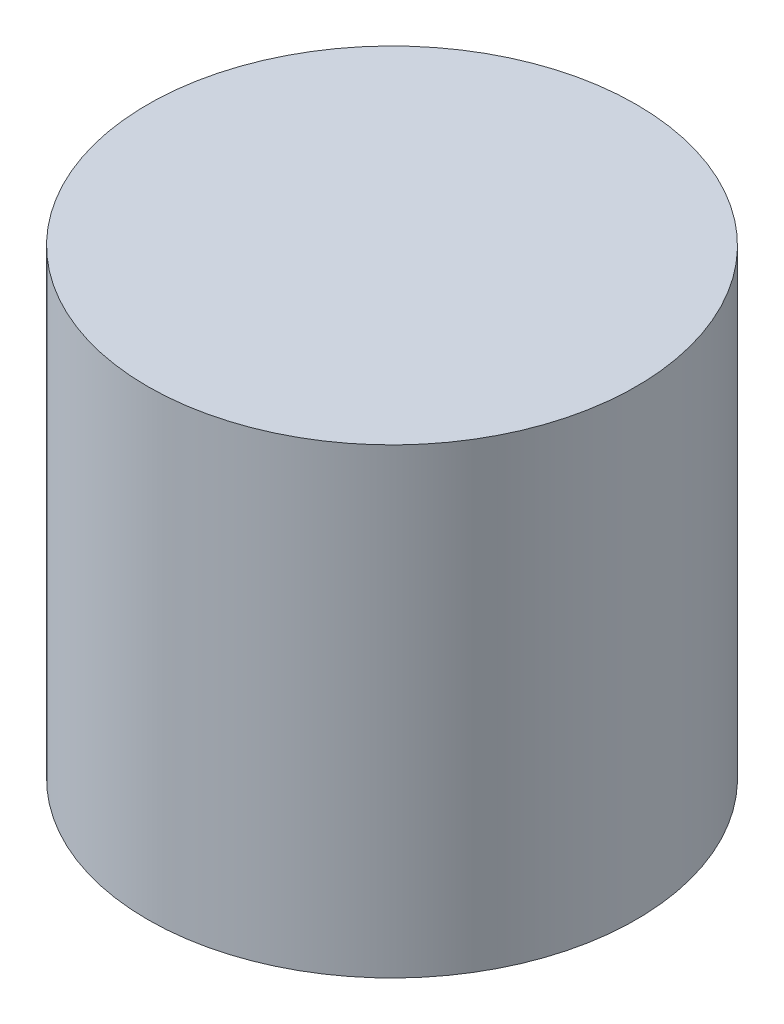
from build123d import *

# Parameters (mm, degrees)
SKETCH1_R           = 15.875
BOSS_EXTRUDE1_DEPTH = 30


with BuildPart() as part:
    # Sketch1 → Boss-Extrude1 (new body)
    with BuildSketch(Plane(origin=(0, 0, 0), x_dir=(1, 0, 0), z_dir=(0, 1, 0))):
        Circle(SKETCH1_R)
    extrude(amount=BOSS_EXTRUDE1_DEPTH)


solid = part.part
